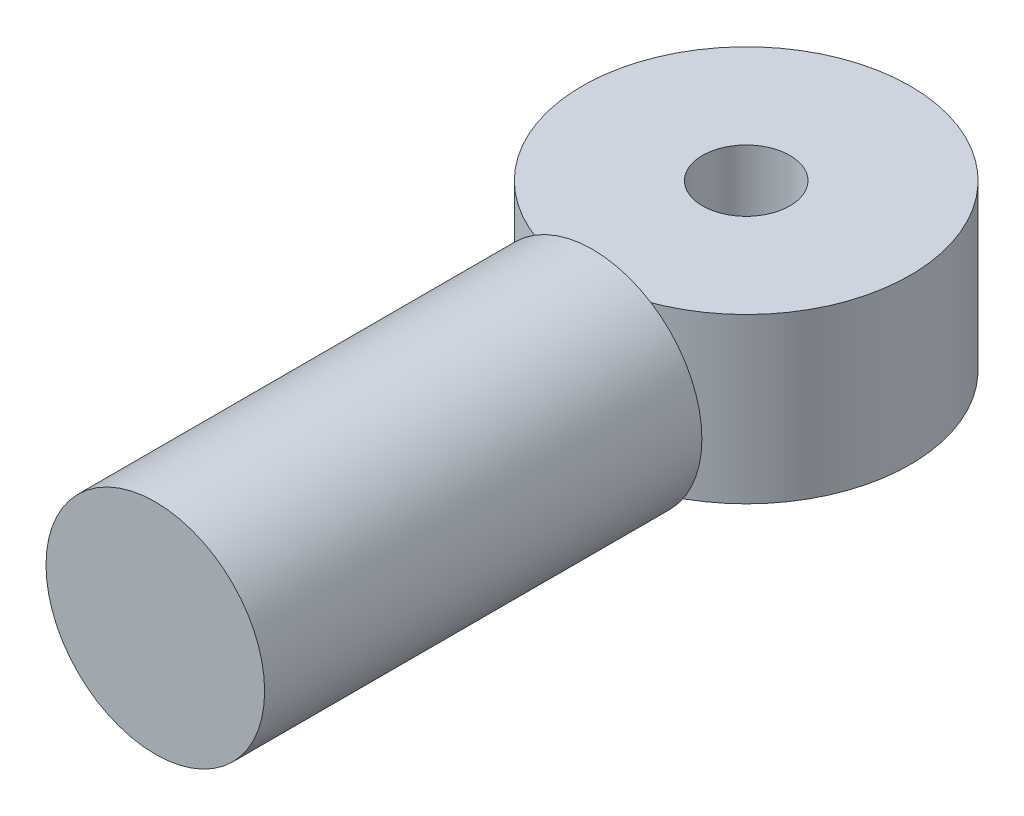
from build123d import *

# Parameters (mm, degrees)
SKETCH2_R           = 10
BOSS_EXTRUDE1_DEPTH = 40
SKETCH4_R           = 15
SKETCH4_R_2         = 4
BOSS_EXTRUDE2_DEPTH = 7.5


with BuildPart() as part:
    # Sketch2 → Boss-Extrude1 (new body)
    with BuildSketch(Plane.XY):
        Circle(SKETCH2_R)
    extrude(amount=BOSS_EXTRUDE1_DEPTH)

    # Sketch4 → Boss-Extrude2 (add, symmetric)
    with BuildSketch(Plane(origin=(0, 0, 0), x_dir=(1, 0, 0), z_dir=(0, 1, 0))):
        with Locations((-0.917156345, 14.971934552)):
            Circle(SKETCH4_R)
        with Locations((-0.917156345, 14.971934552)):
            Circle(SKETCH4_R_2, mode=Mode.SUBTRACT)
    extrude(amount=BOSS_EXTRUDE2_DEPTH, both=True)


solid = part.part
